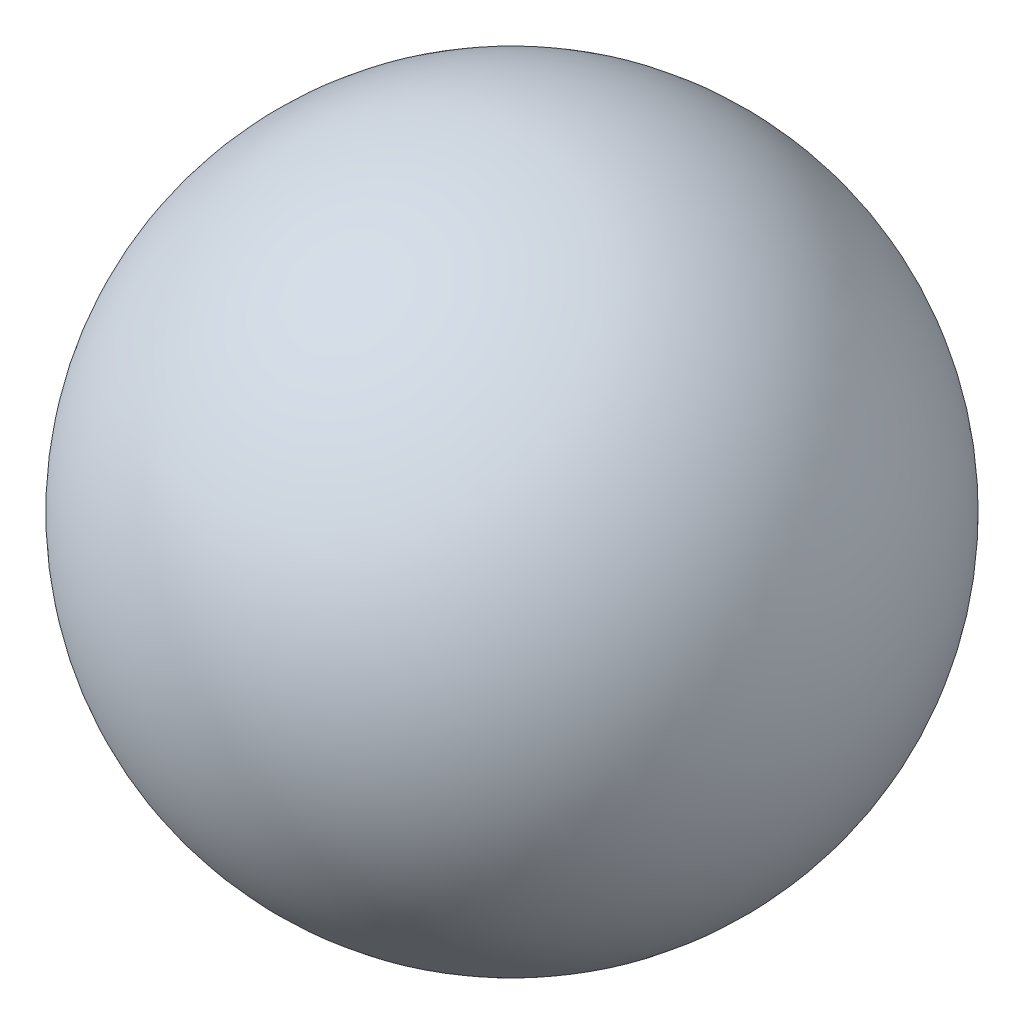
from build123d import *


with BuildPart() as part:
    # Sketch2 one side → Revolve3 (revolve)
    with BuildSketch(Plane(origin=(-2.698032141, 34.47576391, 6.761653582), x_dir=(0, 0, 1), z_dir=(1, 0, 0))):
        with BuildLine():
            Line((30.543493837, -17.323571421), (30.543493837, 39.676428579))
            ThreePointArc((30.543493837, 39.676428579), (2.043493837, 11.176428579), (30.543493837, -17.323571421))
        make_face()
    revolve(axis=Axis((-2.698032141, 51.799335332, 37.305147419), (0, -1, 0)))


solid = part.part
